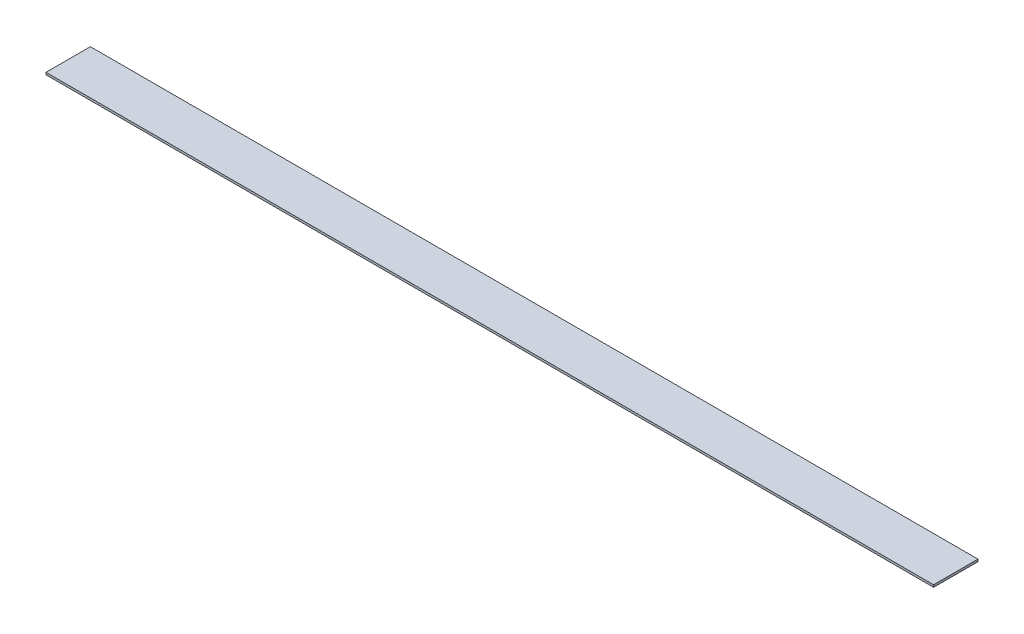
from build123d import *

# Parameters (mm, degrees)
CROQUIS1_W              = 40000
CROQUIS1_H              = 2000
SALIENTE_EXTRUIR1_DEPTH = 100


with BuildPart() as part:
    # Croquis1 → Saliente-Extruir1 (new body)
    with BuildSketch(Plane(origin=(0, 0, 0), x_dir=(1, 0, 0), z_dir=(0, 1, 0))):
        Rectangle(CROQUIS1_W, CROQUIS1_H)
    extrude(amount=SALIENTE_EXTRUIR1_DEPTH)


solid = part.part
